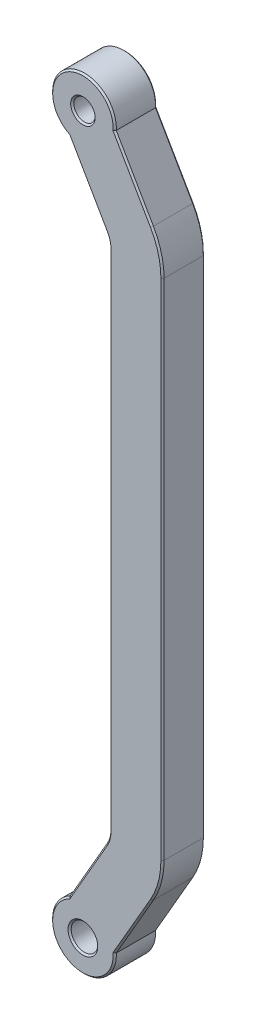
from build123d import *

# Parameters (mm, degrees)
SKETCH_1_R          = 6
EXTRUDE_1_DEPTH     = 8
EXTRUDE_1_2_DEPTH   = 8
EXTRUDE_1_3_DEPTH   = 8
SKETCH_3_R          = 2.5
CUT_EXTRUDE_1_DEPTH = 9
SKETCH_4_R          = 2
CUT_EXTRUDE_2_DEPTH = 9
SKETCH_5_R          = 4
CUT_EXTRUDE_3_DEPTH = 4.5
CHAMFER_1_SIZE      = 0.3


with BuildPart() as part:
    # 草图1 → Extrude 1 (new body)
    with BuildSketch(Plane.XY):
        Circle(SKETCH_1_R)
    extrude(amount=EXTRUDE_1_DEPTH)



with BuildPart() as body_2:
    # 草图1 → Extrude 1 2 (new body)
    with BuildSketch(Plane.XY):
        with Locations((0, 135)):
            Circle(SKETCH_1_R)
    extrude(amount=EXTRUDE_1_2_DEPTH)


with BuildPart() as part_1:
    add(part.part)

    add(body_2.part)  # Extrude 1 3 merges body 2
    # 草图2 → Extrude 1 3 (add)
    with BuildSketch(Plane.XY):
        with BuildLine():
            Line((-4.330127019, 132.5), (4.330127019, 117.5))
            ThreePointArc((4.330127019, 117.5), (4.829629131, 116.294095226), (5, 115))
            Line((5, 115), (5, 20))
            ThreePointArc((5, 20), (4.829629131, 18.705904774), (4.330127019, 17.5))
            Line((4.330127019, 17.5), (-4.330127019, 2.5))
            Line((-4.330127019, 2.5), (4.330127019, -2.5))
            Line((4.330127019, -2.5), (12.990381057, 12.5))
            ThreePointArc((12.990381057, 12.5), (14.488887394, 16.117714323), (15, 20))
            Line((15, 20), (15, 115))
            ThreePointArc((15, 115), (14.488887394, 118.882285677), (12.990381057, 122.5))
            Line((12.990381057, 122.5), (4.330127019, 137.5))
            Line((4.330127019, 137.5), (-4.330127019, 132.5))
        make_face()
    extrude(amount=EXTRUDE_1_3_DEPTH)

    # 草图3 → 切除-拉伸1 (cut, through all)
    with BuildSketch(Plane.XY.offset(8)):
        Circle(SKETCH_3_R)
    extrude(amount=-CUT_EXTRUDE_1_DEPTH, mode=Mode.SUBTRACT)

    # 草图4 → 切除-拉伸2 (cut, through all)
    with BuildSketch(Plane(origin=(0, 0, 0), x_dir=(-1, 0, 0), z_dir=(0, 0, -1))):
        with Locations((0, 135)):
            Circle(SKETCH_4_R)
    extrude(amount=-CUT_EXTRUDE_2_DEPTH, mode=Mode.SUBTRACT)

    # 草图5 → 切除-拉伸3 (cut)
    with BuildSketch(Plane(origin=(0, 0, 0), x_dir=(-1, 0, 0), z_dir=(0, 0, -1))):
        with Locations((0, 135)):
            Circle(SKETCH_5_R)
    extrude(amount=-CUT_EXTRUDE_3_DEPTH, mode=Mode.SUBTRACT)

    # 倒角1
    chamfer_1_edges = [part_1.edges().sort_by_distance(p)[0] for p in [
        (0.829156198, 11.436140662, 0),
        (9.489410235, 6.436140662, 8),
        (14.488887394, 16.117714323, 8),
        (15, 67.5, 8),
        (14.488887394, 118.882285677, 8),
        (4.829629131, 116.294095226, 0),
        (5, 67.5, 0),
        (4.829629131, 18.705904774, 0),
        (9.489410235, 6.436140662, 0),
        (14.488887394, 118.882285677, 0),
        (15, 67.5, 0),
        (14.488887394, 16.117714323, 0),
        (4.829629131, 116.294095226, 8),
        (5, 67.5, 8),
        (4.829629131, 18.705904774, 8),
        (0.829156198, 11.436140662, 8),
        (0.829156198, 123.563859338, 8),
        (0.829156198, 123.563859338, 0),
        (9.489410235, 128.563859338, 8),
        (9.489410235, 128.563859338, 0),
        (-3, 140.196152423, 0),
        (-3, 140.196152423, 8),
        (-2.5, 0, 0),
        (-2.5, 0, 8),
        (-3, -5.196152423, 0),
        (2, 135, 8),
        (4, 135, 0),
        (-3, -5.196152423, 8),
    ]]
    chamfer(chamfer_1_edges, length=CHAMFER_1_SIZE)


solid = part_1.part
